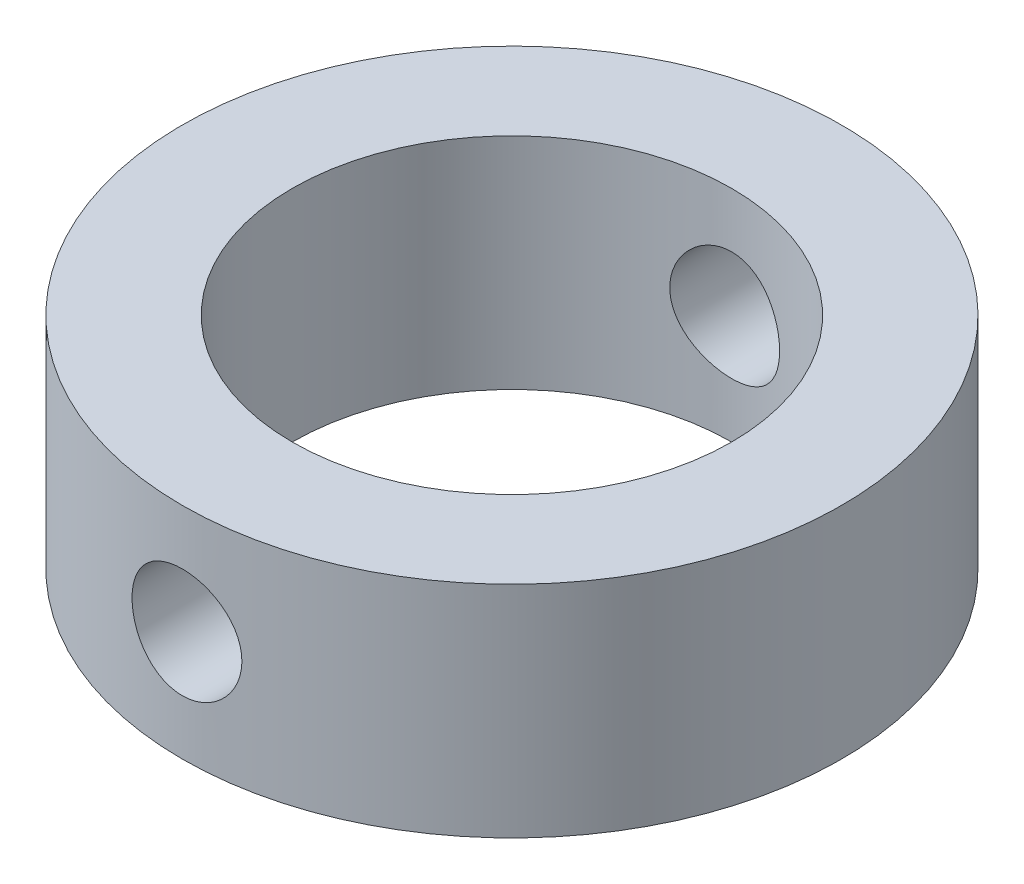
from build123d import *

# Parameters (mm, degrees)
SKETCH1_R               = 12
SKETCH1_R_2             = 8
BOSS_EXTRUDE1_DEPTH     = 8
SKETCH2_R               = 2
CUT_EXTRUDE1_DEPTH      = 18
CUT_EXTRUDE1_DEPTH_BACK = 17


with BuildPart() as part:
    # Sketch1 → Boss-Extrude1 (new body)
    with BuildSketch(Plane(origin=(0, 0, 0), x_dir=(1, 0, 0), z_dir=(0, 1, 0))):
        Circle(SKETCH1_R)
        Circle(SKETCH1_R_2, mode=Mode.SUBTRACT)
    extrude(amount=BOSS_EXTRUDE1_DEPTH)

    # Sketch2 → Cut-Extrude1 (cut, two sides)
    with BuildSketch(Plane.XY) as cut_extrude1_sk:
        with Locations((0, 4)):
            Circle(SKETCH2_R)
    extrude(amount=CUT_EXTRUDE1_DEPTH, mode=Mode.SUBTRACT)
    extrude(cut_extrude1_sk.sketch, amount=-CUT_EXTRUDE1_DEPTH_BACK, mode=Mode.SUBTRACT)


solid = part.part
